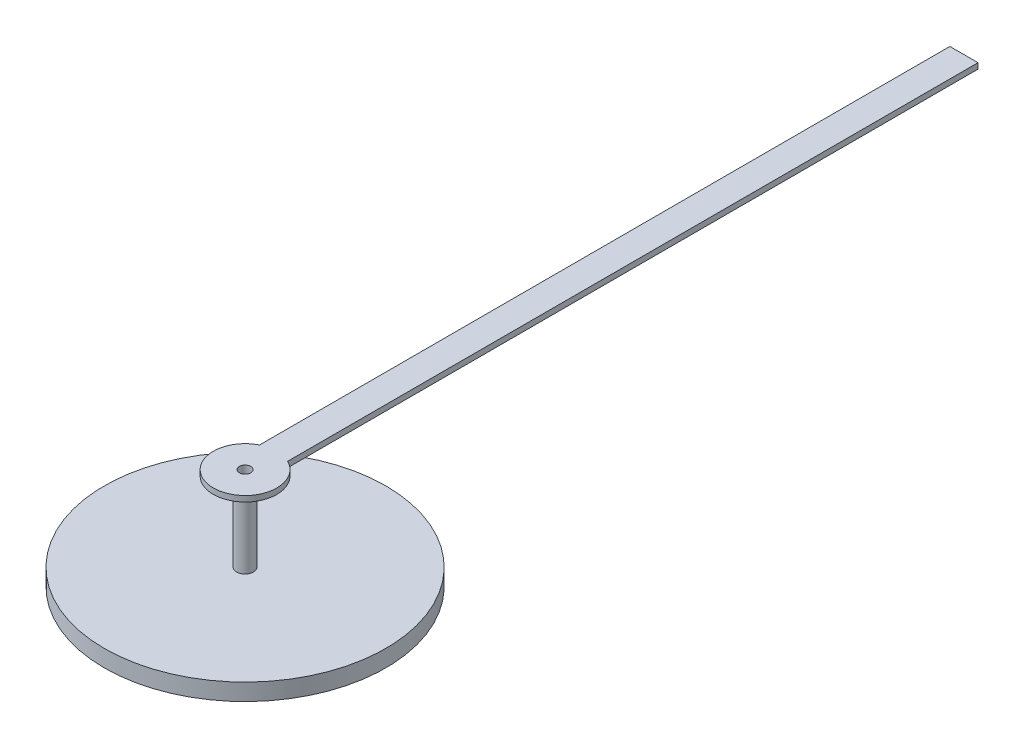
from build123d import *

# Parameters (mm, degrees)
BOSS_EXTRUDE1_DEPTH = 0.1
SKETCH2_R           = 0.15
BOSS_EXTRUDE2_DEPTH = 1.5
SKETCH3_R           = 2.5
BOSS_EXTRUDE3_DEPTH = 0.3
SKETCH4_R           = 0.1
CUT_EXTRUDE1_DEPTH  = 2.8


with BuildPart() as part:
    # Sketch1 → Boss-Extrude1 (new body)
    with BuildSketch(Plane(origin=(0, 0, 0), x_dir=(1, 0, 0), z_dir=(0, 1, 0))):
        with BuildLine():
            Line((-0.25, 12.763947624), (0.25, 12.763947624))
            Line((0.25, 12.763947624), (0.25, 0.505972083))
            ThreePointArc((0.25, 0.505972083), (0, -0.564364907), (-0.25, 0.505972083))
            Line((-0.25, 0.505972083), (-0.25, 12.763947624))
        make_face()
    extrude(amount=BOSS_EXTRUDE1_DEPTH)

    # Sketch2 → Boss-Extrude2 (add)
    with BuildSketch(Plane.XZ.offset(-0.1)):
        Circle(SKETCH2_R)
    extrude(amount=BOSS_EXTRUDE2_DEPTH)

    # Sketch3 → Boss-Extrude3 (add)
    with BuildSketch(Plane.XZ.offset(1.4)):
        Circle(SKETCH3_R)
    extrude(amount=BOSS_EXTRUDE3_DEPTH)

    # Sketch4 → Cut-Extrude1 (cut, through all)
    with BuildSketch(Plane(origin=(0, 0.1, 0), x_dir=(1, 0, 0), z_dir=(0, 1, 0))):
        Circle(SKETCH4_R)
    extrude(amount=-CUT_EXTRUDE1_DEPTH, mode=Mode.SUBTRACT)


solid = part.part
